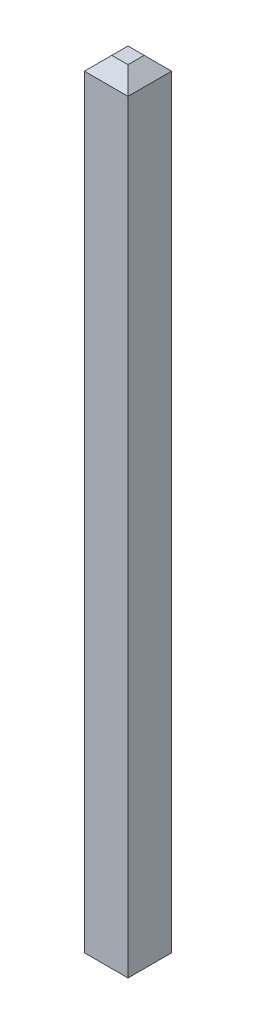
from build123d import *

# Parameters (mm, degrees)
PIN_DRAWING_W = 0.636
PIN_DRAWING_H = 0.636
PIN_DEPTH     = 11.54
CHAMFER2_SIZE = 0.2


with BuildPart() as part:
    # pin_drawing → pin (new body)
    with BuildSketch(Plane(origin=(0, 0, 0), x_dir=(1, 0, 0), z_dir=(0, 1, 0))):
        with Locations((0.318, -0.318)):
            Rectangle(PIN_DRAWING_W, PIN_DRAWING_H)
    extrude(amount=PIN_DEPTH)

    # Chamfer2
    chamfer2_edges = [part.edges().sort_by_distance(p)[0] for p in [
        (0.636, 11.54, 0.318),
        (0.318, 11.54, 0),
        (0, 11.54, 0.318),
        (0.318, 0, 0),
        (0.636, 0, 0.318),
        (0.318, 0, 0.636),
        (0, 0, 0.318),
        (0.318, 11.54, 0.636),
    ]]
    chamfer(chamfer2_edges, length=CHAMFER2_SIZE)


solid = part.part
